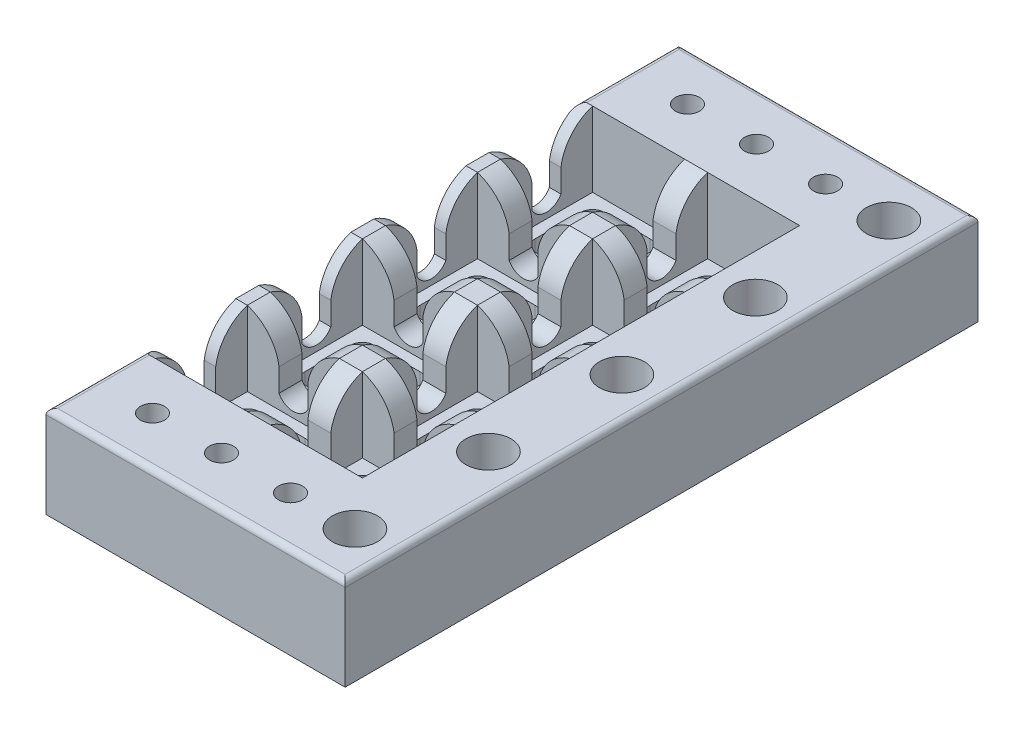
from build123d import *

# Parameters (mm, degrees)
SKETCH2_W            = 25.4
SKETCH2_H            = 25.4
BOSS_EXTRUDE1_DEPTH  = 5.08
BOSS_EXTRUDE2_DEPTH  = 2.54
MIRROR5_COPY_1_DEPTH = 2.54
LPATTERN1_COUNT      = 2
LPATTERN1_PITCH      = 25.4
LPATTERN1_2_COUNT    = 4
LPATTERN1_2_PITCH    = 25.4
BOSS_EXTRUDE4_DEPTH  = 21.59
LPATTERN2_COUNT      = 3
LPATTERN2_PITCH      = 15.24
LPATTERN2_COUNT_DIR2 = 2
LPATTERN2_PITCH_DIR2 = 118.11
LPATTERN3_COUNT      = 5
LPATTERN3_PITCH      = 29.464
CHAMFER1_SIZE        = 1.27
FILLET1_R            = 1.27
CUT_EXTRUDE1_DEPTH   = 1.27


with BuildPart() as part:
    # Sketch2 → Boss-Extrude1 (new body)
    with BuildSketch(Plane(origin=(0, 0, 0), x_dir=(1, 0, 0), z_dir=(0, 1, 0))):
        Rectangle(SKETCH2_W, SKETCH2_H)
        with BuildLine():
            Line((-7.62, -5.08), (-7.62, 5.08))
            ThreePointArc((-7.62, 5.08), (-6.876051224, 6.876051224), (-5.08, 7.62))
            Line((-5.08, 7.62), (5.08, 7.62))
            ThreePointArc((5.08, 7.62), (6.876051224, 6.876051224), (7.62, 5.08))
            Line((7.62, 5.08), (7.62, -5.08))
            ThreePointArc((7.62, -5.08), (6.876051224, -6.876051224), (5.08, -7.62))
            Line((5.08, -7.62), (-5.08, -7.62))
            ThreePointArc((-5.08, -7.62), (-6.876051224, -6.876051224), (-7.62, -5.08))
        make_face(mode=Mode.SUBTRACT)
    extrude(amount=BOSS_EXTRUDE1_DEPTH)

    # Sketch3 → Boss-Extrude2 (add)
    with BuildSketch(Plane(origin=(0, 0, -12.7), x_dir=(-1, 0, 0), z_dir=(0, 0, -1))):
        with BuildLine():
            Line((-12.7, 21.59), (-12.7, 5.08))
            Line((-12.7, 5.08), (12.7, 5.08))
            Line((12.7, 5.08), (12.7, 21.59))
            Line((12.7, 21.59), (10.16, 21.59))
            ThreePointArc((10.16, 21.59), (5.478028065, 18.468976252), (3.175, 13.335))
            Line((3.175, 13.335), (3.175, 8.255))
            ThreePointArc((3.175, 8.255), (0, 6.35), (-3.175, 8.255))
            Line((-3.175, 8.255), (-3.175, 13.335))
            ThreePointArc((-3.175, 13.335), (-5.478028065, 18.468976252), (-10.16, 21.59))
            Line((-10.16, 21.59), (-12.7, 21.59))
        make_face()
    boss_extrude2 = extrude(amount=-BOSS_EXTRUDE2_DEPTH)

    # Mirror4: Boss-Extrude2 across plane
    add(boss_extrude2.mirror(Plane.XY))

    # Mirror5: Boss-Extrude2 across plane
    add(boss_extrude2.mirror(Plane(origin=(0, 0, 0), x_dir=(-0.707106781, 0, 0.707106781), z_dir=(-0.707106781, 0, -0.707106781))))

    # Mirror5 copy 1 sketch → Mirror5 copy 1 (add)
    with BuildSketch(Plane.ZY.offset(12.7)):
        with BuildLine():
            Line((-12.7, 21.59), (-12.7, 5.08))
            Line((-12.7, 5.08), (12.7, 5.08))
            Line((12.7, 5.08), (12.7, 21.59))
            Line((12.7, 21.59), (10.16, 21.59))
            ThreePointArc((10.16, 21.59), (5.478028065, 18.468976252), (3.175, 13.335))
            Line((3.175, 13.335), (3.175, 8.255))
            ThreePointArc((3.175, 8.255), (0, 6.35), (-3.175, 8.255))
            Line((-3.175, 8.255), (-3.175, 13.335))
            ThreePointArc((-3.175, 13.335), (-5.478028065, 18.468976252), (-10.16, 21.59))
            Line((-10.16, 21.59), (-12.7, 21.59))
        make_face()
    extrude(amount=-MIRROR5_COPY_1_DEPTH)


with BuildPart() as lpattern1_1:
    # LPattern1: pattern copy
    add(part.part.moved(Location(Vector(1, 0, 0) * (1 * LPATTERN1_PITCH))))


with BuildPart() as lpattern1_2_1:
    # LPattern1 2: pattern copy
    add(part.part.moved(Location(Vector(0, 0, -1) * (1 * LPATTERN1_2_PITCH))))


with BuildPart() as lpattern1_2_2:
    # LPattern1 2: pattern copy
    add(part.part.moved(Location(Vector(0, 0, -1) * (2 * LPATTERN1_2_PITCH))))


with BuildPart() as lpattern1_2_3:
    # LPattern1 2: pattern copy
    add(part.part.moved(Location(Vector(0, 0, -1) * (3 * LPATTERN1_2_PITCH))))


with BuildPart() as lpattern1_2_4:
    # LPattern1 2: pattern copy
    add(lpattern1_1.part.moved(Location(Vector(0, 0, -1) * (1 * LPATTERN1_2_PITCH))))


with BuildPart() as lpattern1_2_5:
    # LPattern1 2: pattern copy
    add(lpattern1_1.part.moved(Location(Vector(0, 0, -1) * (2 * LPATTERN1_2_PITCH))))


with BuildPart() as lpattern1_2_6:
    # LPattern1 2: pattern copy
    add(lpattern1_1.part.moved(Location(Vector(0, 0, -1) * (3 * LPATTERN1_2_PITCH))))


with BuildPart() as lpattern1_1_1:
    add(lpattern1_1.part)

    # Combine1: union LPattern1 2_1, LPattern1 2_4, LPattern1 2_2, LPattern1 2_5, LPattern1 2_3, part, LPattern1 2_6
    add(lpattern1_2_1.part)
    add(lpattern1_2_4.part)
    add(lpattern1_2_2.part)
    add(lpattern1_2_5.part)
    add(lpattern1_2_3.part)
    add(part.part)
    add(lpattern1_2_6.part)

    # Sketch6 → Boss-Extrude4 (add)
    with BuildSketch(Plane(origin=(0, 0, 0), x_dir=(1, 0, 0), z_dir=(0, 1, 0))):
        Polygon((38.1, 88.9), (-12.7, 88.9), (-12.7, 107.95), (53.34, 107.95), (53.34, -31.75), (-12.7, -31.75), (-12.7, -12.7), (38.1, -12.7), align=None)
        Polygon((38.1, 88.9), (-12.7, 88.9), (-12.7, 86.36), (35.56, 86.36), (35.56, -10.16), (-12.7, -10.16), (-12.7, -12.7), (38.1, -12.7), align=None)
    extrude(amount=BOSS_EXTRUDE4_DEPTH)

    # Sketch10 → Cut-Revolve1 (revolve, cut)
    with BuildSketch(Plane.XY.offset(-97.155)):
        Polygon((0, 11.147815582), (0, 21.59), (2.658601222, 21.59), (2.658601222, 13.342349834), align=None)
    cut_revolve1 = revolve(axis=Axis((0, 11.147815582, -97.155), (0, 1, 0)), mode=Mode.SUBTRACT)

    # LPattern2: Cut-Revolve1 3 × 2
    with Locations(*[(i * LPATTERN2_PITCH, 0, j * LPATTERN2_PITCH_DIR2) for i in range(LPATTERN2_COUNT) for j in range(LPATTERN2_COUNT_DIR2) if (i, j) != (0, 0)]):
        add(cut_revolve1, mode=Mode.SUBTRACT)

    # Sketch11 → Cut-Revolve2 (revolve, cut)
    with BuildSketch(Plane.ZY.offset(-44.45)):
        Polygon((-97.155, 21.59), (-97.155, 9.532979008), (-92.179507073, 12.663624285), (-92.179507073, 21.59), align=None)
    cut_revolve2 = revolve(axis=Axis((44.45, 21.59, -97.155), (0, -1, 0)), mode=Mode.SUBTRACT)

    # LPattern3: Cut-Revolve2 ×5
    with Locations(*[(0, 0, i * LPATTERN3_PITCH) for i in range(1, LPATTERN3_COUNT)]):
        add(cut_revolve2, mode=Mode.SUBTRACT)

    # Chamfer1
    chamfer1_edges = [lpattern1_1_1.edges().sort_by_distance(p)[0] for p in [
        (-12.7, 0, -38.1),
        (20.32, 0, -107.95),
        (53.34, 0, -38.1),
        (20.32, 0, 31.75),
    ]]
    chamfer(chamfer1_edges, length=CHAMFER1_SIZE)

    # Fillet1
    fillet1_edges = [lpattern1_1_1.edges().sort_by_distance(p)[0] for p in [
        (-12.7, 21.59, -97.155),
        (-12.7, 21.59, 20.955),
        (20.32, 21.59, 31.75),
        (53.34, 21.59, -38.1),
        (20.32, 21.59, -107.95),
    ]]
    fillet(fillet1_edges, radius=FILLET1_R)

    # Sketch12 → Cut-Extrude1 (cut)
    with BuildSketch(Plane.ZY.offset(12.7)):
        with BuildLine():
            Line((-98.850077426, 8.324855433), (-98.850077426, 7.698026389))
            add(Edge.make_bspline(
                [(-98.850077426, 7.698026389), (-98.932393171, 7.631934335), (-99.105397198, 7.493027842), (-99.386073, 7.291889219), (-99.698200683, 7.096025877), (-100.037088002, 6.91619795), (-100.40123952, 6.761598603), (-100.719340315, 6.657612598), (-100.982660951, 6.589732733), (-101.185654423, 6.558482389), (-101.391313636, 6.535681135), (-101.529501973, 6.533175013), (-101.599020441, 6.531914256)],
                knots=[0, 0, 0, 0, 0.00031666, 0.000665528, 0.001035237, 0.00142137, 0.001815202, 0.002220509, 0.002424346, 0.002630159, 0.002836091, 0.003044568, 0.003044568, 0.003044568, 0.003044568], degree=3))
            add(Edge.make_bspline(
                [(-101.599020441, 6.531914256), (-101.735728542, 6.535463397), (-102.003621516, 6.542418288), (-102.396639178, 6.591566259), (-102.769804124, 6.675924654), (-103.123661745, 6.790579677), (-103.454510233, 6.940343055), (-103.761294153, 7.120853435), (-104.044505443, 7.330658853), (-104.301157585, 7.571666274), (-104.530421067, 7.842857189), (-104.735751118, 8.140479457), (-104.910239195, 8.468174041), (-105.05834662, 8.823002075), (-105.172311721, 9.205323123), (-105.257355905, 9.612151313), (-105.305669433, 10.043676651), (-105.312651007, 10.33946277), (-105.316221728, 10.490742381)],
                knots=[0, 0, 0, 0, 0.000410089, 0.00080361, 0.001185908, 0.00155633, 0.001917584, 0.002273128, 0.002622264, 0.00297282, 0.003326822, 0.003685726, 0.004055481, 0.004438529, 0.004837339, 0.005250441, 0.005683948, 0.006137774, 0.006137774, 0.006137774, 0.006137774], degree=3))
            add(Edge.make_bspline(
                [(-105.316221728, 10.490742381), (-105.312949809, 10.637968499), (-105.306539996, 10.926390025), (-105.253610701, 11.348675301), (-105.16340236, 11.749727737), (-105.042307667, 12.130418545), (-104.885130728, 12.485657889), (-104.703563539, 12.816445846), (-104.493839165, 13.120043551), (-104.256874334, 13.396063445), (-103.993605584, 13.642600587), (-103.708237861, 13.862213436), (-103.398705771, 14.049210116), (-103.068220349, 14.207503257), (-102.718909346, 14.333889028), (-102.352468278, 14.422232175), (-101.97257003, 14.478907588), (-101.71420132, 14.485002085), (-101.583262169, 14.488090727)],
                knots=[0, 0, 0, 0, 0.000441579, 0.00086507, 0.001274145, 0.001673373, 0.00206147, 0.002437652, 0.002803862, 0.003166408, 0.003526864, 0.003884069, 0.004244711, 0.004609659, 0.004981844, 0.005356823, 0.005738896, 0.006131493, 0.006131493, 0.006131493, 0.006131493], degree=3))
            add(Edge.make_bspline(
                [(-101.583262169, 14.488090727), (-101.483392695, 14.485795972), (-101.273926309, 14.480982949), (-100.95108249, 14.448876365), (-100.614422367, 14.405320555), (-100.274548504, 14.35324959), (-99.942201304, 14.293106784), (-99.626674366, 14.224931633), (-99.339670076, 14.156317081), (-99.159334918, 14.10900696), (-99.075945992, 14.087130249)],
                knots=[0, 0, 0, 0, 0.000299591, 0.000628363, 0.000972587, 0.001318033, 0.00165975, 0.001985651, 0.002286326, 0.002544952, 0.002544952, 0.002544952, 0.002544952], degree=3))
            Line((-99.075945992, 14.087130249), (-99.075945992, 12.246914256))
            Line((-99.075945992, 12.246914256), (-99.587214375, 12.246914256))
            Line((-99.587214375, 12.246914256), (-99.839346728, 13.285209293))
            add(Edge.make_bspline(
                [(-99.839346728, 13.285209293), (-99.848766656, 13.314028035), (-99.867185501, 13.370377504), (-99.933698435, 13.431141837), (-100.003269372, 13.479326098), (-100.052171405, 13.507848192), (-100.075720809, 13.521583374)],
                knots=[0, 0, 0, 0, 8.9434e-05, 0.000174871, 0.000262801, 0.000344478, 0.000344478, 0.000344478, 0.000344478], degree=3))
            add(Edge.make_bspline(
                [(-100.075720809, 13.521583374), (-100.135994711, 13.551711852), (-100.258150579, 13.612772613), (-100.451860388, 13.687888179), (-100.652965473, 13.758627101), (-100.862522059, 13.819885243), (-101.078064923, 13.869394682), (-101.298308663, 13.901479129), (-101.520350362, 13.923916997), (-101.669584593, 13.926501731), (-101.744346728, 13.927796609)],
                knots=[0, 0, 0, 0, 0.000202047, 0.000409485, 0.000622673, 0.000841538, 0.001064119, 0.001285497, 0.001508854, 0.001733082, 0.001733082, 0.001733082, 0.001733082], degree=3))
            add(Edge.make_bspline(
                [(-101.744346728, 13.927796609), (-101.830256317, 13.925431647), (-101.999961035, 13.920759929), (-102.249241436, 13.884021832), (-102.486865417, 13.819549505), (-102.714232577, 13.73517174), (-102.92697272, 13.621516133), (-103.12596562, 13.48521138), (-103.308022686, 13.321403277), (-103.47449388, 13.133687003), (-103.624126325, 12.920697372), (-103.753056457, 12.681784853), (-103.867594753, 12.41969256), (-103.962992636, 12.131888541), (-104.041083178, 11.818436247), (-104.093097681, 11.478490836), (-104.127674687, 11.113034672), (-104.130922867, 10.860856691), (-104.132600404, 10.730618301)],
                knots=[0, 0, 0, 0, 0.000257677, 0.000509011, 0.000753646, 0.00099526, 0.001234931, 0.001475343, 0.001717154, 0.001967688, 0.0022266, 0.002496156, 0.002780787, 0.003083655, 0.003404699, 0.003748687, 0.004114394, 0.004504991, 0.004504991, 0.004504991, 0.004504991], degree=3))
            add(Edge.make_bspline(
                [(-104.132600404, 10.730618301), (-104.130060816, 10.593401003), (-104.125135949, 10.327303947), (-104.092584629, 9.941036951), (-104.035411914, 9.58159982), (-103.954540739, 9.247855771), (-103.852624331, 8.939535791), (-103.726120625, 8.657174558), (-103.576970552, 8.401348672), (-103.404485462, 8.171884683), (-103.209711715, 7.969623239), (-102.993414979, 7.795623012), (-102.759886713, 7.643585329), (-102.5017821, 7.527031905), (-102.227019156, 7.430122053), (-101.931193834, 7.365487956), (-101.615955496, 7.324041114), (-101.398971343, 7.318946593), (-101.287356838, 7.316326021)],
                knots=[0, 0, 0, 0, 0.000411648, 0.000798285, 0.001161844, 0.001502428, 0.001827444, 0.002134649, 0.002428939, 0.00271399, 0.002993841, 0.003268936, 0.003545304, 0.003827305, 0.00411635, 0.004417936, 0.004733927, 0.005068646, 0.005068646, 0.005068646, 0.005068646], degree=3))
            add(Edge.make_bspline(
                [(-101.287356838, 7.316326021), (-101.219610799, 7.317764555), (-101.087340767, 7.320573206), (-100.894099422, 7.339719548), (-100.710692731, 7.372718863), (-100.483253407, 7.435726176), (-100.220226289, 7.536944093), (-99.929022922, 7.678086868), (-99.671607179, 7.839482631), (-99.444633565, 8.008351919), (-99.247284915, 8.172112101), (-99.123174374, 8.276360863), (-99.065440478, 8.324855433)],
                knots=[0, 0, 0, 0, 0.000203227, 0.000396789, 0.000581899, 0.00076157, 0.001104008, 0.001425844, 0.001730967, 0.002013923, 0.002273986, 0.002500187, 0.002500187, 0.002500187, 0.002500187], degree=3))
            Line((-99.065440478, 8.324855433), (-98.850077426, 8.324855433))
        make_face()
        with BuildLine():
            Line((-98.037650956, 6.980149551), (-97.23573, 7.202516279))
            add(Edge.make_bspline(
                [(-97.23573, 7.202516279), (-97.203759646, 7.214657814), (-97.143358281, 7.237596733), (-97.069979859, 7.301487354), (-97.019972601, 7.388732755), (-97.016805219, 7.45681862), (-97.015114191, 7.493168852)],
                knots=[0, 0, 0, 0, 0.00010187, 0.000192462, 0.000286508, 0.000394228, 0.000394228, 0.000394228, 0.000394228], degree=3))
            Line((-97.015114191, 7.493168852), (-97.015114191, 13.420030065))
            add(Edge.make_bspline(
                [(-97.015114191, 13.420030065), (-97.017315913, 13.455369523), (-97.021504254, 13.522595854), (-97.076319626, 13.606931151), (-97.148684171, 13.667832177), (-97.206874579, 13.689454875), (-97.23573, 13.700177124)],
                knots=[0, 0, 0, 0, 0.000104499, 0.000198789, 0.000292049, 0.000383785, 0.000383785, 0.000383785, 0.000383785], degree=3))
            Line((-97.23573, 13.700177124), (-98.037650956, 13.927796609))
            Line((-98.037650956, 13.927796609), (-98.037650956, 14.26397308))
            Line((-98.037650956, 14.26397308), (-94.912260331, 14.26397308))
            Line((-94.912260331, 14.26397308), (-94.912260331, 13.927796609))
            Line((-94.912260331, 13.927796609), (-95.712430367, 13.700177124))
            add(Edge.make_bspline(
                [(-95.712430367, 13.700177124), (-95.743085874, 13.689635551), (-95.803775875, 13.668765952), (-95.878773602, 13.60749581), (-95.933608181, 13.522547014), (-95.937830348, 13.455352695), (-95.940049853, 13.420030065)],
                knots=[0, 0, 0, 0, 9.6571e-05, 0.000191185, 0.000285475, 0.000389974, 0.000389974, 0.000389974, 0.000389974], degree=3))
            Line((-95.940049853, 13.420030065), (-95.940049853, 7.493168852))
            add(Edge.make_bspline(
                [(-95.940049853, 7.493168852), (-95.937955184, 7.45555909), (-95.934031462, 7.385108681), (-95.880015995, 7.295580997), (-95.803661475, 7.233993815), (-95.743047482, 7.213080124), (-95.712430367, 7.202516279)],
                knots=[0, 0, 0, 0, 0.000111428, 0.000208726, 0.00030334, 0.000399911, 0.000399911, 0.000399911, 0.000399911], degree=3))
            Line((-95.712430367, 7.202516279), (-94.912260331, 6.980149551))
            Line((-94.912260331, 6.980149551), (-94.912260331, 6.64397308))
            Line((-94.912260331, 6.64397308), (-98.037650956, 6.64397308))
            Line((-98.037650956, 6.64397308), (-98.037650956, 6.980149551))
        make_face()
        with BuildLine():
            Line((-94.003533309, 6.980149551), (-93.227876139, 7.202516279))
            add(Edge.make_bspline(
                [(-93.227876139, 7.202516279), (-93.199121695, 7.213964274), (-93.141361222, 7.236960429), (-93.06658654, 7.298010362), (-93.014226726, 7.387230714), (-93.009649954, 7.456829789), (-93.007260331, 7.493168852)],
                knots=[0, 0, 0, 0, 9.2451e-05, 0.000185711, 0.000284526, 0.000392488, 0.000392488, 0.000392488, 0.000392488], degree=3))
            Line((-93.007260331, 7.493168852), (-93.007260331, 13.420030065))
            add(Edge.make_bspline(
                [(-93.007260331, 13.420030065), (-93.009593592, 13.455306303), (-93.014012102, 13.522109089), (-93.066481242, 13.606683174), (-93.138334998, 13.669200904), (-93.197707671, 13.689740524), (-93.227876139, 13.700177124)],
                knots=[0, 0, 0, 0, 0.000104499, 0.000197891, 0.00028981, 0.000384764, 0.000384764, 0.000384764, 0.000384764], degree=3))
            Line((-93.227876139, 13.700177124), (-94.003533309, 13.927796609))
            Line((-94.003533309, 13.927796609), (-94.003533309, 14.26397308))
            Line((-94.003533309, 14.26397308), (-90.914911985, 14.26397308))
            Line((-90.914911985, 14.26397308), (-90.914911985, 13.927796609))
            Line((-90.914911985, 13.927796609), (-91.706327426, 13.700177124))
            add(Edge.make_bspline(
                [(-91.706327426, 13.700177124), (-91.735876145, 13.690930585), (-91.796163866, 13.672065035), (-91.869287196, 13.608822477), (-91.923348277, 13.522860664), (-91.929159944, 13.455315858), (-91.932195992, 13.420030065)],
                knots=[0, 0, 0, 0, 9.2019e-05, 0.000187745, 0.000283535, 0.000388312, 0.000388312, 0.000388312, 0.000388312], degree=3))
            Line((-91.932195992, 13.420030065), (-91.932195992, 7.204267198))
            Line((-91.932195992, 7.204267198), (-89.17800022, 7.204267198))
            add(Edge.make_bspline(
                [(-89.17800022, 7.204267198), (-89.162088125, 7.205175154), (-89.131162531, 7.206939793), (-89.087262808, 7.223964158), (-89.049813484, 7.250063393), (-89.017624113, 7.28243116), (-88.990893655, 7.319662034), (-88.970709107, 7.36220408), (-88.952673138, 7.40702138), (-88.945310052, 7.438766072), (-88.941626139, 7.454648631)],
                knots=[0, 0, 0, 0, 4.7566e-05, 9.2445e-05, 0.000139067, 0.000183638, 0.000228824, 0.000275806, 0.000324581, 0.000373419, 0.000373419, 0.000373419, 0.000373419], degree=3))
            Line((-88.941626139, 7.454648631), (-88.645720809, 8.997208374))
            Line((-88.645720809, 8.997208374), (-88.123946912, 8.997208374))
            Line((-88.123946912, 8.997208374), (-88.123946912, 6.64397308))
            Line((-88.123946912, 6.64397308), (-94.003533309, 6.64397308))
            Line((-94.003533309, 6.64397308), (-94.003533309, 6.980149551))
        make_face()
        with BuildLine():
            Line((-87.288758492, 8.997208374), (-86.77749011, 8.997208374))
            Line((-86.77749011, 8.997208374), (-86.481584779, 7.892378411))
            add(Edge.make_bspline(
                [(-86.481584779, 7.892378411), (-86.471821087, 7.866535475), (-86.449957715, 7.808666618), (-86.38450924, 7.735642533), (-86.310266778, 7.674305721), (-86.261590623, 7.63496703), (-86.239957941, 7.617484109)],
                knots=[0, 0, 0, 0, 8.2312e-05, 0.000184317, 0.000288581, 0.000371985, 0.000371985, 0.000371985, 0.000371985], degree=3))
            add(Edge.make_bspline(
                [(-86.239957941, 7.617484109), (-86.18258415, 7.581774505), (-86.065794341, 7.509084207), (-85.879847722, 7.411263958), (-85.68401933, 7.323809765), (-85.48313624, 7.243944818), (-85.279444116, 7.17991004), (-85.075722015, 7.129602038), (-84.873986159, 7.099139435), (-84.740098211, 7.094484376), (-84.67463625, 7.092208374)],
                knots=[0, 0, 0, 0, 0.000202691, 0.000412597, 0.000629669, 0.000845891, 0.001060748, 0.001269688, 0.001474964, 0.001671348, 0.001671348, 0.001671348, 0.001671348], degree=3))
            add(Edge.make_bspline(
                [(-84.67463625, 7.092208374), (-84.610947129, 7.092778761), (-84.486174575, 7.093896197), (-84.304625046, 7.115444094), (-84.131902262, 7.141120708), (-83.969832805, 7.184134945), (-83.818918004, 7.237871495), (-83.678233695, 7.301103774), (-83.550559731, 7.375897238), (-83.435495097, 7.463030733), (-83.332283221, 7.55928007), (-83.239903102, 7.664544987), (-83.162559874, 7.781593785), (-83.098146076, 7.908095625), (-83.044506606, 8.043069407), (-83.008544114, 8.188547887), (-82.984865735, 8.342166817), (-82.982633095, 8.447911352), (-82.981497463, 8.501698264)],
                knots=[0, 0, 0, 0, 0.000190922, 0.000374034, 0.000547896, 0.000714371, 0.000876083, 0.00102809, 0.001176433, 0.001318959, 0.001460187, 0.001599206, 0.001738093, 0.001879831, 0.002024523, 0.002172732, 0.002328485, 0.002489722, 0.002489722, 0.002489722, 0.002489722], degree=3))
            add(Edge.make_bspline(
                [(-82.981497463, 8.501698264), (-82.984668797, 8.579625356), (-82.990827403, 8.730956705), (-83.043821733, 8.946820034), (-83.133191506, 9.141172913), (-83.258223247, 9.311736348), (-83.411836904, 9.463565139), (-83.58994087, 9.599283508), (-83.790311735, 9.723849116), (-83.937205433, 9.789738934), (-84.012788823, 9.823642198)],
                knots=[0, 0, 0, 0, 0.00023353, 0.000453505, 0.000661887, 0.000871332, 0.001084283, 0.001307722, 0.001541953, 0.00179022, 0.00179022, 0.00179022, 0.00179022], degree=3))
            add(Edge.make_bspline(
                [(-84.012788823, 9.823642198), (-84.086014597, 9.85365957), (-84.23064636, 9.912948331), (-84.451102123, 9.986553559), (-84.669858027, 10.056837263), (-84.887359052, 10.125691889), (-85.103159651, 10.1974138), (-85.318367502, 10.263127559), (-85.53063768, 10.337191554), (-85.669361989, 10.392741877), (-85.739195073, 10.420705617)],
                knots=[0, 0, 0, 0, 0.000237351, 0.000468804, 0.000696935, 0.000926732, 0.001153197, 0.001379127, 0.001601735, 0.001827386, 0.001827386, 0.001827386, 0.001827386], degree=3))
            add(Edge.make_bspline(
                [(-85.739195073, 10.420705617), (-85.841092558, 10.466322082), (-86.039328533, 10.555066418), (-86.305775071, 10.732860732), (-86.541379003, 10.931451331), (-86.70645432, 11.122579958), (-86.819926789, 11.28586799), (-86.891143178, 11.416193633), (-86.953036421, 11.551794272), (-87.004287274, 11.693887211), (-87.042100207, 11.843028845), (-87.069973814, 11.997475863), (-87.088526681, 12.1577512), (-87.090102133, 12.266705116), (-87.090904632, 12.322203779)],
                knots=[0, 0, 0, 0, 0.000334389, 0.000650535, 0.000957246, 0.001256366, 0.001404978, 0.001553104, 0.001701199, 0.001851839, 0.002005572, 0.002162179, 0.002322471, 0.002488892, 0.002488892, 0.002488892, 0.002488892], degree=3))
            add(Edge.make_bspline(
                [(-87.090904632, 12.322203779), (-87.088648991, 12.397660286), (-87.084180277, 12.547149293), (-87.045488834, 12.766561941), (-86.987164563, 12.978885041), (-86.899894863, 13.180067894), (-86.792861015, 13.370740453), (-86.668597152, 13.550165326), (-86.52533832, 13.715555095), (-86.365676648, 13.868439325), (-86.188252007, 14.007319173), (-85.994215311, 14.129052046), (-85.784766916, 14.235147451), (-85.561689413, 14.325385549), (-85.326721298, 14.399666394), (-85.080723058, 14.449369641), (-84.827278158, 14.482323593), (-84.654898233, 14.486155337), (-84.567830184, 14.488090727)],
                knots=[0, 0, 0, 0, 0.000226201, 0.000448133, 0.000666514, 0.000885386, 0.00110409, 0.00132169, 0.001538952, 0.001759387, 0.001983901, 0.002213672, 0.002445456, 0.002687362, 0.002934911, 0.003183529, 0.003439361, 0.00370046, 0.00370046, 0.00370046, 0.00370046], degree=3))
            add(Edge.make_bspline(
                [(-84.567830184, 14.488090727), (-84.466213033, 14.486436128), (-84.265019767, 14.483160162), (-83.967335637, 14.456225573), (-83.677434509, 14.422813988), (-83.397218865, 14.374958541), (-83.125329686, 14.327087359), (-82.864518153, 14.26259568), (-82.610388485, 14.200575702), (-82.443895373, 14.15628045), (-82.361672095, 14.134405065)],
                knots=[0, 0, 0, 0, 0.000304786, 0.00060345, 0.000896204, 0.001180026, 0.001456128, 0.001724115, 0.001985706, 0.002240945, 0.002240945, 0.002240945, 0.002240945], degree=3))
            Line((-82.361672095, 14.134405065), (-82.361672095, 12.246914256))
            Line((-82.361672095, 12.246914256), (-82.872940478, 12.246914256))
            Line((-82.872940478, 12.246914256), (-83.142582022, 13.297465727))
            add(Edge.make_bspline(
                [(-83.142582022, 13.297465727), (-83.15110292, 13.32545712), (-83.169279226, 13.385166807), (-83.238918213, 13.452998743), (-83.309189047, 13.513302843), (-83.357199405, 13.550328483), (-83.378956103, 13.567107271)],
                knots=[0, 0, 0, 0, 8.6489e-05, 0.000184494, 0.000283819, 0.000366131, 0.000366131, 0.000366131, 0.000366131], degree=3))
            add(Edge.make_bspline(
                [(-83.378956103, 13.567107271), (-83.416897144, 13.592643206), (-83.496482495, 13.646207531), (-83.631805462, 13.708353708), (-83.775338869, 13.774014974), (-83.931340521, 13.823351777), (-84.092477704, 13.872188311), (-84.260773458, 13.900536456), (-84.430040099, 13.923952909), (-84.543233585, 13.926522695), (-84.599346728, 13.927796609)],
                knots=[0, 0, 0, 0, 0.000136975, 0.00028732, 0.000445727, 0.000610174, 0.000777568, 0.000950306, 0.00112144, 0.001289674, 0.001289674, 0.001289674, 0.001289674], degree=3))
            add(Edge.make_bspline(
                [(-84.599346728, 13.927796609), (-84.657761319, 13.926996603), (-84.771951276, 13.925432735), (-84.938091273, 13.907204095), (-85.095017145, 13.879564212), (-85.24125553, 13.841101866), (-85.377724662, 13.79438924), (-85.501641864, 13.735646065), (-85.617242731, 13.671571068), (-85.719869257, 13.595978997), (-85.811896278, 13.513686791), (-85.891514569, 13.422563318), (-85.961819732, 13.325250819), (-86.019509999, 13.219777838), (-86.064927973, 13.10928269), (-86.098836082, 12.995038962), (-86.118322657, 12.876158863), (-86.121189772, 12.795604867), (-86.12264636, 12.754680801)],
                knots=[0, 0, 0, 0, 0.000175171, 0.000342427, 0.000500757, 0.000652795, 0.000795664, 0.000932751, 0.001063707, 0.001191536, 0.001314263, 0.001433352, 0.001553847, 0.001673744, 0.001793076, 0.001911649, 0.002030531, 0.002153295, 0.002153295, 0.002153295, 0.002153295], degree=3))
            add(Edge.make_bspline(
                [(-86.12264636, 12.754680801), (-86.120205668, 12.683337545), (-86.115331813, 12.540871142), (-86.078691838, 12.330734517), (-86.012929594, 12.127611913), (-85.907081395, 11.936613706), (-85.759761203, 11.759200702), (-85.605526489, 11.625255389), (-85.459069422, 11.528186855), (-85.334886922, 11.455473878), (-85.195551382, 11.391024404), (-85.096861903, 11.353888036), (-85.045831103, 11.334685396)],
                knots=[0, 0, 0, 0, 0.000213963, 0.000427267, 0.000637669, 0.000851611, 0.001078042, 0.001326265, 0.001461268, 0.001604822, 0.001757564, 0.001921113, 0.001921113, 0.001921113, 0.001921113], degree=3))
            add(Edge.make_bspline(
                [(-85.045831103, 11.334685396), (-84.977592278, 11.310044101), (-84.841996888, 11.261080096), (-84.638038546, 11.19001016), (-84.43307523, 11.125556727), (-84.228263876, 11.05537095), (-84.019988877, 10.986218261), (-83.805936173, 10.912137479), (-83.583664241, 10.830538313), (-83.434709257, 10.766910719), (-83.357945073, 10.734120139)],
                knots=[0, 0, 0, 0, 0.000217657, 0.0004325, 0.000647891, 0.00086217, 0.001081985, 0.001306246, 0.001541711, 0.001792092, 0.001792092, 0.001792092, 0.001792092], degree=3))
            add(Edge.make_bspline(
                [(-83.357945073, 10.734120139), (-83.270279993, 10.695278645), (-83.092951836, 10.61671041), (-82.838398737, 10.471679656), (-82.596029187, 10.300763873), (-82.418977521, 10.125462645), (-82.2927552, 9.969415063), (-82.206055597, 9.841130846), (-82.131839846, 9.700923668), (-82.0657992, 9.55105322), (-82.01337241, 9.389257976), (-81.974491584, 9.214118687), (-81.951881458, 9.025237253), (-81.949618471, 8.894549301), (-81.948455184, 8.82736922)],
                knots=[0, 0, 0, 0, 0.000287503, 0.000581558, 0.00087751, 0.001174661, 0.001325332, 0.001479273, 0.001638299, 0.001800616, 0.001970048, 0.002147618, 0.002338082, 0.00253956, 0.00253956, 0.00253956, 0.00253956], degree=3))
            add(Edge.make_bspline(
                [(-81.948455184, 8.82736922), (-81.950676935, 8.756080674), (-81.955121181, 8.613479695), (-81.984960509, 8.400215926), (-82.038903575, 8.189744478), (-82.109845627, 7.981740054), (-82.201631682, 7.779512148), (-82.32073812, 7.588974289), (-82.46315443, 7.410097222), (-82.62920476, 7.24273364), (-82.818054042, 7.088500164), (-83.033368985, 6.950649832), (-83.273192363, 6.829583625), (-83.536965448, 6.721354783), (-83.827680383, 6.635426997), (-84.146714782, 6.575209634), (-84.493424832, 6.538354742), (-84.734071631, 6.534109163), (-84.858482757, 6.531914256)],
                knots=[0, 0, 0, 0, 0.00021387, 0.000427812, 0.000644389, 0.000864768, 0.001086479, 0.001309011, 0.001537068, 0.00177107, 0.002014995, 0.00226706, 0.002536435, 0.002819959, 0.003121331, 0.003444118, 0.003792745, 0.004165892, 0.004165892, 0.004165892, 0.004165892], degree=3))
            add(Edge.make_bspline(
                [(-84.858482757, 6.531914256), (-84.948450674, 6.534018281), (-85.132990219, 6.538333994), (-85.414112836, 6.571986592), (-85.705043714, 6.622346075), (-86.004095362, 6.682813163), (-86.308250293, 6.755951405), (-86.615386352, 6.832884338), (-86.920196591, 6.921957451), (-87.123021544, 6.981853684), (-87.223974485, 7.011666095)],
                knots=[0, 0, 0, 0, 0.000269846, 0.0005535, 0.000848259, 0.001155589, 0.001468592, 0.001786667, 0.002105339, 0.002421136, 0.002421136, 0.002421136, 0.002421136], degree=3))
            Line((-87.223974485, 7.011666095), (-87.288758492, 8.997208374))
        make_face()
    extrude(amount=-CUT_EXTRUDE1_DEPTH, mode=Mode.SUBTRACT)


solid = lpattern1_1_1.part
